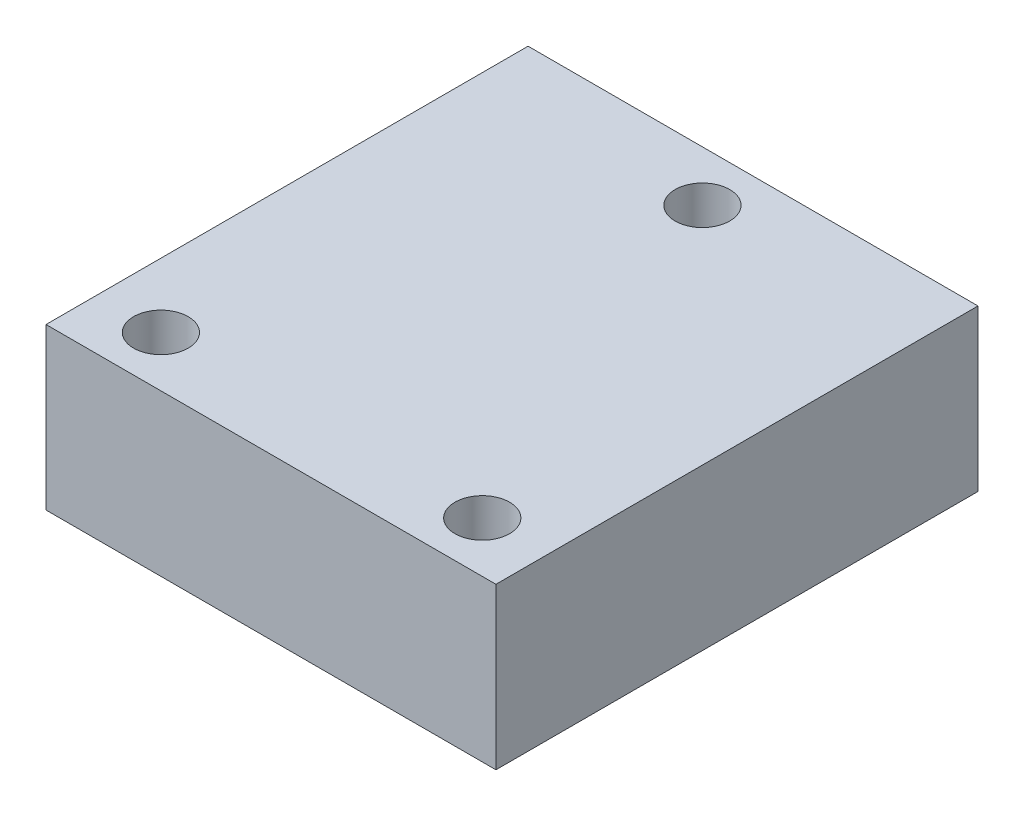
from build123d import *

# Parameters (mm, degrees)
SKETCH_1_W          = 28
SKETCH_1_H          = 30
EXTRUDE_1_DEPTH     = 10
SKETCH_2_R          = 1.7
CUT_EXTRUDE_1_DEPTH = 11


with BuildPart() as part:
    # 草图1 → 凸台-拉伸1 (new body)
    with BuildSketch(Plane(origin=(0, 0, 0), x_dir=(1, 0, 0), z_dir=(0, 1, 0))):
        Rectangle(SKETCH_1_W, SKETCH_1_H)
    extrude(amount=EXTRUDE_1_DEPTH)

    # 草图2 → 切除-拉伸1 (cut, through all)
    with BuildSketch(Plane(origin=(0, 10, 0), x_dir=(1, 0, 0), z_dir=(0, 1, 0))):
        with Locations((0, 11.85)):
            Circle(SKETCH_2_R)
        with Locations((-10, -11.85)):
            Circle(SKETCH_2_R)
        with Locations((10, -11.85)):
            Circle(SKETCH_2_R)
    extrude(amount=-CUT_EXTRUDE_1_DEPTH, mode=Mode.SUBTRACT)


solid = part.part
